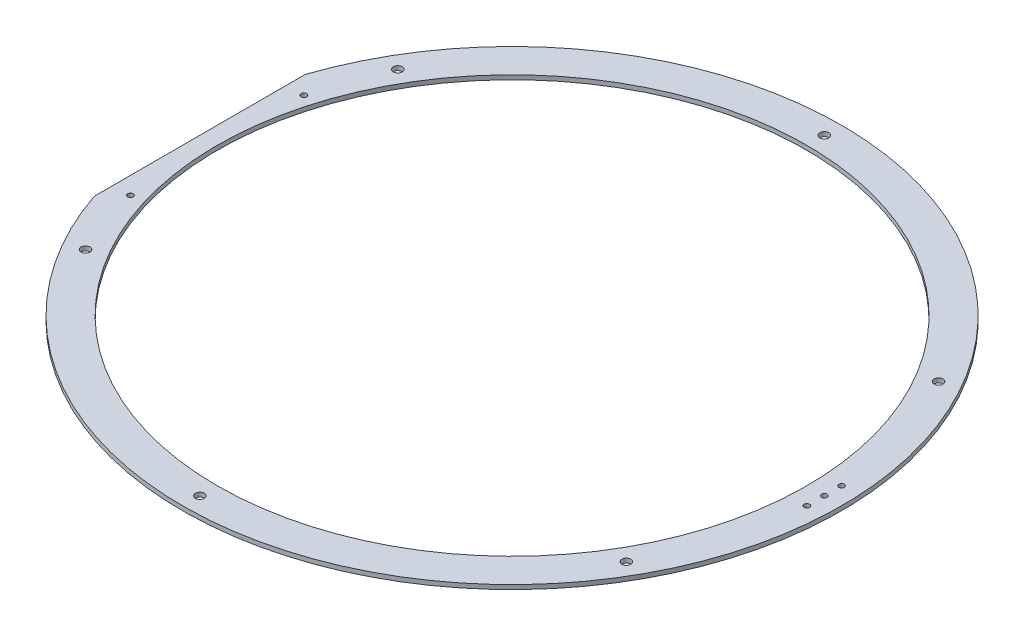
from build123d import *

# Parameters (mm, degrees)
SKETCH1_R           = 3.2639
SKETCH1_R_2         = 2.0193
SKETCH1_R_3         = 215.9
BOSS_EXTRUDE1_DEPTH = 3.175


with BuildPart() as part:
    # Sketch1 → Boss-Extrude1 (new body)
    with BuildSketch(Plane(origin=(0, 0, 0), x_dir=(1, 0, 0), z_dir=(0, 1, 0))):
        with BuildLine():
            ThreePointArc((241.3, 0), (39.144028917, 238.103832393), (-228.600000001, 77.251084131))
            Line((-228.6, 77.251084131), (-228.6, -77.251084131))
            ThreePointArc((-228.600000001, -77.251084131), (39.144028917, -238.103832393), (241.3, 0))
        make_face()
        with Locations((0, -228.6)):
            Circle(SKETCH1_R, mode=Mode.SUBTRACT)
        with Locations((-197.973407305, -114.3)):
            Circle(SKETCH1_R, mode=Mode.SUBTRACT)
        with Locations((-215.9, -63.5)):
            Circle(SKETCH1_R_2, mode=Mode.SUBTRACT)
        with Locations((197.973407305, -114.3)):
            Circle(SKETCH1_R, mode=Mode.SUBTRACT)
        with Locations((228.6, -12.7)):
            Circle(SKETCH1_R_2, mode=Mode.SUBTRACT)
        with Locations((-215.9, 63.5)):
            Circle(SKETCH1_R_2, mode=Mode.SUBTRACT)
        with Locations((-197.973407305, 114.3)):
            Circle(SKETCH1_R, mode=Mode.SUBTRACT)
        Circle(SKETCH1_R_3, mode=Mode.SUBTRACT)
        with Locations((0, 228.6)):
            Circle(SKETCH1_R, mode=Mode.SUBTRACT)
        with Locations((197.973407305, 114.3)):
            Circle(SKETCH1_R, mode=Mode.SUBTRACT)
        with Locations((228.6, 0)):
            Circle(SKETCH1_R_2, mode=Mode.SUBTRACT)
        with Locations((228.6, 12.7)):
            Circle(SKETCH1_R_2, mode=Mode.SUBTRACT)
    extrude(amount=BOSS_EXTRUDE1_DEPTH)


solid = part.part
